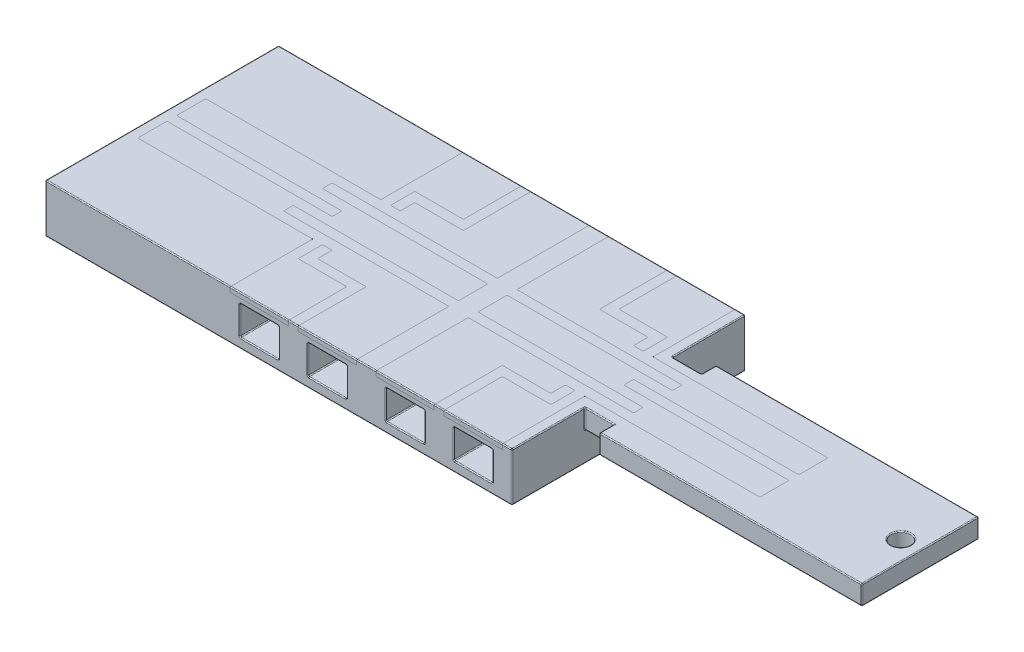
from build123d import *

# Parameters (mm, degrees)
SKETCH_BEAM_SURFACES_W                     = 12
SKETCH_BEAM_SURFACES_H                     = 12
BEAM_SURFACES_DEPTH                        = 2
SKETCH_FREE_END_HOLE_R                     = 1
FREE_END_HOLE_DEPTH                        = 2
FREE_END_HOLE_FILLETS_R                    = 0.1
SKETCH_CANTILEVER_BASE_W                   = 48
SKETCH_CANTILEVER_BASE_H                   = 24
CANTILEVER_BASE_DEPTH                      = 3
CANTILEVER_FILLETS_R                       = 0.1
SPACE_FOR_CONDUCTIVE_TRACES_DEPTH          = 0.5
SPACE_FOR_CONDUCTIVE_TRACES_FILLETS_R      = 0.1
SPACE_FOR_CONDUCTIVE_TRACES_FILLETS_OF_S_R = 0.1
CONDUCTIVE_TRACES_DEPTH                    = 0.5
CONDUCTIVE_TRACES_FILLETS_R                = 0.1
ELECTRICAL_CONTACTS_FILLETS_R              = 0.1
CUT_EXTRUDE0_START                         = -1
SKETCH0_W                                  = 4
SKETCH0_H                                  = 5
CUT_EXTRUDE0_DEPTH                         = 3
FILLET0_R                                  = 0.1
FILLET0_OF_MIRROR0_R                       = 0.1


with BuildPart() as part:
    # Sketch_ Beam Surfaces → Beam Surfaces (new body)
    with BuildSketch(Plane(origin=(0, 0, 0), x_dir=(1, 0, 0), z_dir=(0, 1, 0))):
        Polygon((18, -6), (33, -6), (33, 6), (18, 6), (18, 4.5), (15, 4.5), (15, 12), (-33, 12), (-33, -12), (15, -12), (15, -4.5), (18, -4.5), align=None)
        with Locations((39, 0)):
            Rectangle(SKETCH_BEAM_SURFACES_W, SKETCH_BEAM_SURFACES_H)
    extrude(amount=-BEAM_SURFACES_DEPTH)

    # Sketch_ Free End Hole → Free End Hole (cut)
    with BuildSketch(Plane(origin=(0, 0, 0), x_dir=(1, 0, 0), z_dir=(0, 1, 0))):
        with Locations((43, 0)):
            Circle(SKETCH_FREE_END_HOLE_R)
    extrude(amount=-FREE_END_HOLE_DEPTH, mode=Mode.SUBTRACT)

    # Free End Hole Fillets
    free_end_hole_fillets_edges = [part.edges().sort_by_distance(p)[0] for p in [
        (42, 0, 0),
        (42, -2, 0),
    ]]
    fillet(free_end_hole_fillets_edges, radius=FREE_END_HOLE_FILLETS_R)

    # Sketch_ Cantilever Base → Cantilever Base (add)
    with BuildSketch(Plane.XZ.offset(2)):
        with Locations((-9, 0)):
            Rectangle(SKETCH_CANTILEVER_BASE_W, SKETCH_CANTILEVER_BASE_H)
    extrude(amount=CANTILEVER_BASE_DEPTH)

    # Cantilever Fillets
    cantilever_fillets_edges = [part.edges().sort_by_distance(p)[0] for p in [
        (45, -2, 0),
        (18, 0, 5.25),
        (16.5, 0, 4.5),
        (15, 0, 8.25),
        (-9, 0, 12),
        (-33, 0, 0),
        (31.5, -2, -6),
        (-9, 0, -12),
        (15, 0, -8.25),
        (16.5, 0, -4.5),
        (18, 0, -5.25),
        (31.5, 0, -6),
        (45, 0, 0),
        (31.5, 0, 6),
        (18, -2, -5.25),
        (18, -1, 6),
        (15, -1, 4.5),
        (15, -2.5, 12),
        (-33, -2.5, 12),
        (-33, -2.5, -12),
        (15, -2.5, -12),
        (15, -1, -4.5),
        (18, -1, -4.5),
        (18, -1, -6),
        (45, -1, -6),
        (45, -1, 6),
        (16.5, -2, -4.5),
        (31.5, -2, 6),
        (15, -2, 0),
        (16.5, -2, 4.5),
        (-33, -5, 0),
        (-9, -5, -12),
        (15, -5, 0),
        (-9, -5, 12),
        (18, -2, 5.25),
    ]]
    fillet(cantilever_fillets_edges, radius=CANTILEVER_FILLETS_R)

    # Sketch_ Conductive Traces → Space for Conductive Traces (cut)
    with BuildSketch(Plane(origin=(0, 0, 0), x_dir=(1, 0, 0), z_dir=(0, 1, 0))):
        Polygon((18, -2.5), (1, -2.5), (1, -12), (7, -12), (7, -5), (12, -5), (12, -3.5), (13, -3.5), (13, -6), (8, -6), (8, -12), (14, -12), (14, -3.5), (32, -3.5), (32, -0.5), (15, -0.5), (15, 0.5), (32, 0.5), (32, 3.5), (14, 3.5), (14, 12), (8, 12), (8, 6), (13, 6), (13, 3.5), (12, 3.5), (12, 5), (7, 5), (7, 12), (1, 12), (1, 2.5), (18, 2.5), (18, 1.5), (1, 1.5), (1, -1.5), (18, -1.5), align=None)
    space_for_conductive_traces = extrude(amount=-SPACE_FOR_CONDUCTIVE_TRACES_DEPTH, mode=Mode.SUBTRACT)

    # Space for Conductive Traces Fillets
    space_for_conductive_traces_fillets_edges = [part.edges().sort_by_distance(p)[0] for p in [
        (13, -0.25, 3.5),
        (12, -0.25, 3.5),
        (12, -0.25, 5),
        (7, -0.25, 5),
        (1, -0.25, 2.5),
        (18, -0.25, 2.5),
        (18, -0.25, 1.5),
        (1, -0.25, 1.5),
        (1, -0.25, -1.5),
        (18, -0.25, -1.5),
        (18, -0.25, -2.5),
        (1, -0.25, -2.5),
        (7, -0.25, -5),
        (12, -0.25, -5),
        (12, -0.25, -3.5),
        (13, -0.25, -3.5),
        (13, -0.25, -6),
        (8, -0.25, -6),
        (14, -0.25, -3.5),
        (32, -0.25, -3.5),
        (32, -0.25, -0.5),
        (15, -0.25, -0.5),
        (15, -0.25, 0.5),
        (32, -0.25, 0.5),
        (32, -0.25, 3.5),
        (14, -0.25, 3.5),
        (8, -0.25, 6),
        (13, -0.25, 6),
    ]]
    fillet(space_for_conductive_traces_fillets_edges, radius=SPACE_FOR_CONDUCTIVE_TRACES_FILLETS_R)

    # Space for mid_str_4T_sensing_elem Refere: Space for Conductive Traces across plane
    add(space_for_conductive_traces.mirror(Plane(origin=(0, 0, 0), x_dir=(0, 0, 1), z_dir=(1, 0, 0))), mode=Mode.SUBTRACT)

    # Space for Conductive Traces Fillets of S
    space_for_conductive_traces_fillets_of_s_edges = [part.edges().sort_by_distance(p)[0] for p in [
        (-13, -0.25, 3.5),
        (-12, -0.25, 3.5),
        (-12, -0.25, 5),
        (-7, -0.25, 5),
        (-1, -0.25, 2.5),
        (-18, -0.25, 2.5),
        (-18, -0.25, 1.5),
        (-1, -0.25, 1.5),
        (-1, -0.25, -1.5),
        (-18, -0.25, -1.5),
        (-18, -0.25, -2.5),
        (-1, -0.25, -2.5),
        (-7, -0.25, -5),
        (-12, -0.25, -5),
        (-12, -0.25, -3.5),
        (-13, -0.25, -3.5),
        (-13, -0.25, -6),
        (-8, -0.25, -6),
        (-14, -0.25, -3.5),
        (-32, -0.25, -3.5),
        (-32, -0.25, -0.5),
        (-15, -0.25, -0.5),
        (-15, -0.25, 0.5),
        (-32, -0.25, 0.5),
        (-32, -0.25, 3.5),
        (-14, -0.25, 3.5),
        (-8, -0.25, 6),
        (-13, -0.25, 6),
    ]]
    fillet(space_for_conductive_traces_fillets_of_s_edges, radius=SPACE_FOR_CONDUCTIVE_TRACES_FILLETS_OF_S_R)

    # Sketch0 → Cut-Extrude0 (cut)
    with BuildSketch(Plane(origin=(0, 0, 0), x_dir=(1, 0, 0), z_dir=(0, 1, 0)).offset(CUT_EXTRUDE0_START)):
        with Locations((4, 9.5)):
            Rectangle(SKETCH0_W, SKETCH0_H)
        with Locations((11, 9.5)):
            Rectangle(SKETCH0_W, SKETCH0_H)
        with Locations((11, -9.5)):
            Rectangle(SKETCH0_W, SKETCH0_H)
        with Locations((4, -9.5)):
            Rectangle(SKETCH0_W, SKETCH0_H)
    cut_extrude0 = extrude(amount=-CUT_EXTRUDE0_DEPTH, mode=Mode.SUBTRACT)

    # Fillet0
    fillet0_edges = [part.edges().sort_by_distance(p)[0] for p in [
        (2, -4, 9.5),
        (2, -2.5, 12),
        (4, -4, 7),
        (2, -2.5, 7),
        (6, -4, 9.5),
        (6, -2.5, 7),
        (4, -4, 12),
        (6, -2.5, 12),
        (2, -1, 9.5),
        (4, -1, 12),
        (6, -1, 9.5),
        (4, -1, 7),
        (9, -4, 9.5),
        (9, -2.5, 12),
        (11, -4, 7),
        (9, -2.5, 7),
        (13, -4, 9.5),
        (13, -2.5, 7),
        (11, -4, 12),
        (13, -2.5, 12),
        (9, -1, 9.5),
        (11, -1, 12),
        (13, -1, 9.5),
        (11, -1, 7),
        (9, -4, -9.5),
        (9, -2.5, -7),
        (11, -4, -12),
        (9, -2.5, -12),
        (13, -4, -9.5),
        (13, -2.5, -12),
        (11, -4, -7),
        (13, -2.5, -7),
        (9, -1, -9.5),
        (11, -1, -7),
        (13, -1, -9.5),
        (11, -1, -12),
        (2, -4, -9.5),
        (2, -2.5, -7),
        (4, -4, -12),
        (2, -2.5, -12),
        (6, -4, -9.5),
        (6, -2.5, -12),
        (4, -4, -7),
        (6, -2.5, -7),
        (2, -1, -9.5),
        (4, -1, -7),
        (6, -1, -9.5),
        (4, -1, -12),
    ]]
    fillet(fillet0_edges, radius=FILLET0_R)

    # Mirror0: Cut-Extrude0 across plane
    add(cut_extrude0.mirror(Plane(origin=(0, 0, 0), x_dir=(0, 0, 1), z_dir=(1, 0, 0))), mode=Mode.SUBTRACT)

    # Fillet0 of Mirror0
    fillet0_of_mirror0_edges = [part.edges().sort_by_distance(p)[0] for p in [
        (-2, -4, 9.5),
        (-2, -2.5, 12),
        (-4, -4, 7),
        (-2, -2.5, 7),
        (-6, -4, 9.5),
        (-6, -2.5, 7),
        (-4, -4, 12),
        (-6, -2.5, 12),
        (-2, -1, 9.5),
        (-4, -1, 12),
        (-6, -1, 9.5),
        (-4, -1, 7),
        (-9, -4, 9.5),
        (-9, -2.5, 12),
        (-11, -4, 7),
        (-9, -2.5, 7),
        (-13, -4, 9.5),
        (-13, -2.5, 7),
        (-11, -4, 12),
        (-13, -2.5, 12),
        (-9, -1, 9.5),
        (-11, -1, 12),
        (-13, -1, 9.5),
        (-11, -1, 7),
        (-9, -4, -9.5),
        (-9, -2.5, -7),
        (-11, -4, -12),
        (-9, -2.5, -12),
        (-13, -4, -9.5),
        (-13, -2.5, -12),
        (-11, -4, -7),
        (-13, -2.5, -7),
        (-9, -1, -9.5),
        (-11, -1, -7),
        (-13, -1, -9.5),
        (-11, -1, -12),
        (-2, -4, -9.5),
        (-2, -2.5, -7),
        (-4, -4, -12),
        (-2, -2.5, -12),
        (-6, -4, -9.5),
        (-6, -2.5, -12),
        (-4, -4, -7),
        (-6, -2.5, -7),
        (-2, -1, -9.5),
        (-4, -1, -7),
        (-6, -1, -9.5),
        (-4, -1, -12),
    ]]
    fillet(fillet0_of_mirror0_edges, radius=FILLET0_OF_MIRROR0_R)


with BuildPart() as body_2:
    # Conductive Traces Sketch_5 → Conductive Traces (new body)
    with BuildSketch(Plane(origin=(0, 0, 0), x_dir=(1, 0, 0), z_dir=(0, 1, 0))):
        Polygon((18, -2.5), (1, -2.5), (1, -12), (7, -12), (7, -5), (12, -5), (12, -3.5), (13, -3.5), (13, -6), (8, -6), (8, -12), (14, -12), (14, -3.5), (32, -3.5), (32, -0.5), (15, -0.5), (15, 0.5), (32, 0.5), (32, 3.5), (14, 3.5), (14, 12), (8, 12), (8, 6), (13, 6), (13, 3.5), (12, 3.5), (12, 5), (7, 5), (7, 12), (1, 12), (1, 2.5), (18, 2.5), (18, 1.5), (1, 1.5), (1, -1.5), (18, -1.5), align=None)
    extrude(amount=-CONDUCTIVE_TRACES_DEPTH)

    # Conductive Traces Fillets
    conductive_traces_fillets_edges = [body_2.edges().sort_by_distance(p)[0] for p in [
        (12, -0.25, 3.5),
        (12, -0.25, 5),
        (7, -0.25, 5),
        (1, -0.25, 2.5),
        (18, -0.25, 2.5),
        (18, -0.25, 1.5),
        (1, -0.25, 1.5),
        (1, -0.25, -1.5),
        (18, -0.25, -1.5),
        (18, -0.25, -2.5),
        (1, -0.25, -2.5),
        (7, -0.25, -5),
        (12, -0.25, -5),
        (12, -0.25, -3.5),
        (13, -0.25, -3.5),
        (13, -0.25, -6),
        (8, -0.25, -6),
        (32, -0.25, -3.5),
        (32, -0.25, -0.5),
        (15, -0.25, -0.5),
        (15, -0.25, 0.5),
        (32, -0.25, 0.5),
        (32, -0.25, 3.5),
        (8, -0.25, 6),
        (13, -0.25, 6),
        (13, -0.25, 3.5),
    ]]
    fillet(conductive_traces_fillets_edges, radius=CONDUCTIVE_TRACES_FILLETS_R)

    # Electrical Contacts Fillets
    electrical_contacts_fillets_edges = [body_2.edges().sort_by_distance(p)[0] for p in [
        (4, 0, 12),
        (4, 0, -12),
        (11, 0, -12),
        (11, 0, 12),
    ]]
    fillet(electrical_contacts_fillets_edges, radius=ELECTRICAL_CONTACTS_FILLETS_R)


with BuildPart() as body_3:
    # mid_str_4T_sensing_elem Reference: mirrored copy
    add(body_2.part.mirror(Plane(origin=(0, 0, 0), x_dir=(0, 0, 1), z_dir=(1, 0, 0))))


solid = Compound([part.part, body_2.part, body_3.part])
